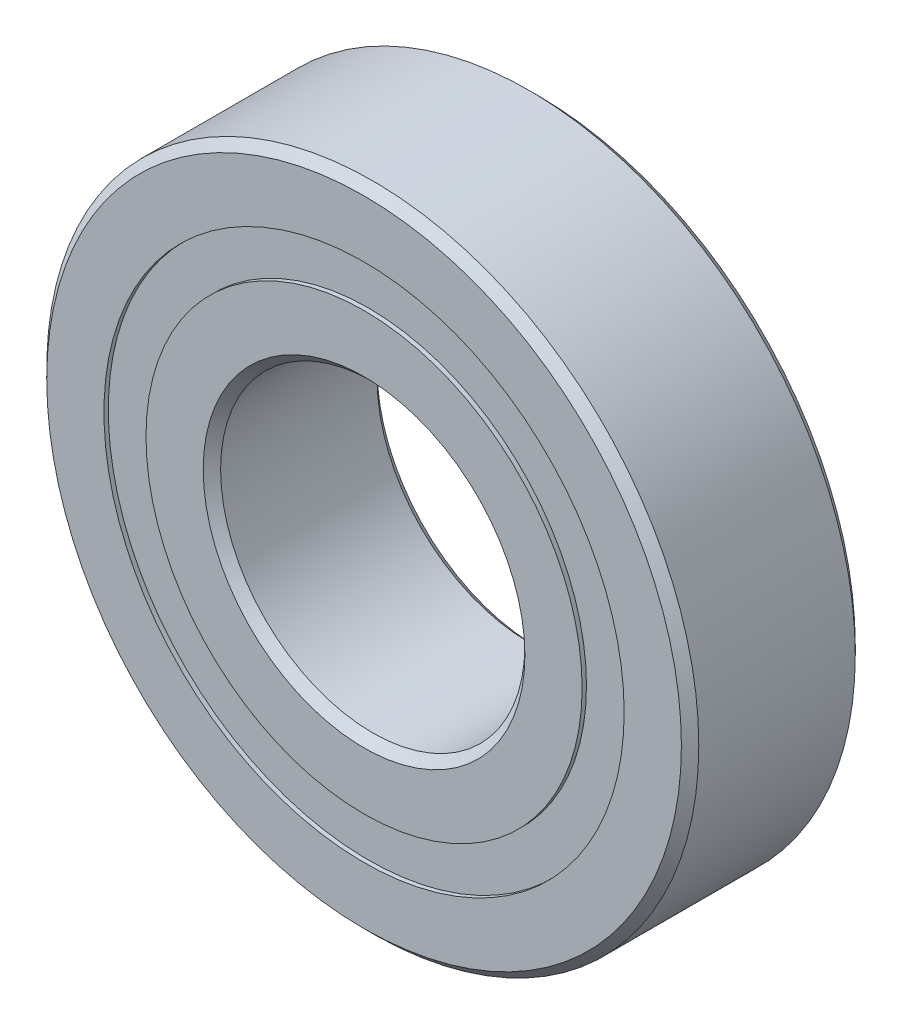
from build123d import *

# Parameters (mm, degrees)
CIRPATTERN1_COUNT = 12
SKETCH5_W         = 2.819764508
SKETCH5_H         = 3.07032967


with BuildPart() as part:
    # Sketch1 → Revolve1 (revolve)
    with BuildSketch(Plane(origin=(0, 0, 0), x_dir=(0, 0, -1), z_dir=(1, 0, 0))):
        with BuildLine():
            Line((5.715, 23.8125), (-5.715, 23.8125))
            Line((-5.715, 23.8125), (-6.35, 23.1775))
            Line((-6.35, 23.1775), (-6.35, 18.997664835))
            Line((-6.35, 18.997664835), (-2.822222222, 18.997664835))
            ThreePointArc((-2.822222222, 18.997664835), (0, 20.675235492), (2.822222222, 18.997664835))
            Line((2.822222222, 18.997664835), (6.35, 18.997664835))
            Line((6.35, 18.997664835), (6.35, 23.1775))
            Line((6.35, 23.1775), (5.715, 23.8125))
        make_face()
    revolve(axis=Axis((0, 0, 6.35), (0, 0, -1)))


with BuildPart() as body_2:
    # Sketch3 → Revolve3 (revolve)
    with BuildSketch(Plane(origin=(0, 0, 0), x_dir=(0, 0, -1), z_dir=(1, 0, 0))):
        with BuildLine():
            Line((-6.35, 15.927335165), (-2.822222222, 15.927335165))
            ThreePointArc((-2.822222222, 15.927335165), (0, 14.249764508), (2.822222222, 15.927335165))
            Line((2.822222222, 15.927335165), (6.35, 15.927335165))
            Line((6.35, 15.927335165), (6.35, 11.7475))
            Line((6.35, 11.7475), (5.715, 11.1125))
            Line((5.715, 11.1125), (-5.715, 11.1125))
            Line((-5.715, 11.1125), (-6.35, 11.7475))
            Line((-6.35, 11.7475), (-6.35, 15.927335165))
        make_face()
    revolve(axis=Axis((0, 0, 6.35), (0, 0, -1)))


with BuildPart() as body_3:
    # Sketch4 → Revolve4 (revolve)
    with BuildSketch(Plane(origin=(0, 0, 0), x_dir=(0, 0, -1), z_dir=(1, 0, 0))):
        with BuildLine():
            Line((-3.212735492, 17.4625), (3.212735492, 17.4625))
            ThreePointArc((3.212735492, 17.4625), (0, 20.675235492), (-3.212735492, 17.4625))
        make_face()
    revolve(axis=Axis((0, 17.4625, 3.212735492), (0, 0, -1)))


with BuildPart() as cirpattern1_1:
    # CirPattern1: pattern copy
    add(body_3.part.rotate(Axis((0, 0, -6.35), (0, 0, 1)), 1 * 360 / CIRPATTERN1_COUNT))


with BuildPart() as cirpattern1_2:
    # CirPattern1: pattern copy
    add(body_3.part.rotate(Axis((0, 0, -6.35), (0, 0, 1)), 2 * 360 / CIRPATTERN1_COUNT))


with BuildPart() as cirpattern1_3:
    # CirPattern1: pattern copy
    add(body_3.part.rotate(Axis((0, 0, -6.35), (0, 0, 1)), 3 * 360 / CIRPATTERN1_COUNT))


with BuildPart() as cirpattern1_4:
    # CirPattern1: pattern copy
    add(body_3.part.rotate(Axis((0, 0, -6.35), (0, 0, 1)), 4 * 360 / CIRPATTERN1_COUNT))


with BuildPart() as cirpattern1_5:
    # CirPattern1: pattern copy
    add(body_3.part.rotate(Axis((0, 0, -6.35), (0, 0, 1)), 5 * 360 / CIRPATTERN1_COUNT))


with BuildPart() as cirpattern1_6:
    # CirPattern1: pattern copy
    add(body_3.part.rotate(Axis((0, 0, -6.35), (0, 0, 1)), 6 * 360 / CIRPATTERN1_COUNT))


with BuildPart() as cirpattern1_7:
    # CirPattern1: pattern copy
    add(body_3.part.rotate(Axis((0, 0, -6.35), (0, 0, 1)), 7 * 360 / CIRPATTERN1_COUNT))


with BuildPart() as cirpattern1_8:
    # CirPattern1: pattern copy
    add(body_3.part.rotate(Axis((0, 0, -6.35), (0, 0, 1)), 8 * 360 / CIRPATTERN1_COUNT))


with BuildPart() as cirpattern1_9:
    # CirPattern1: pattern copy
    add(body_3.part.rotate(Axis((0, 0, -6.35), (0, 0, 1)), 9 * 360 / CIRPATTERN1_COUNT))


with BuildPart() as cirpattern1_10:
    # CirPattern1: pattern copy
    add(body_3.part.rotate(Axis((0, 0, -6.35), (0, 0, 1)), 10 * 360 / CIRPATTERN1_COUNT))


with BuildPart() as cirpattern1_11:
    # CirPattern1: pattern copy
    add(body_3.part.rotate(Axis((0, 0, -6.35), (0, 0, 1)), 11 * 360 / CIRPATTERN1_COUNT))


with BuildPart() as body_15:
    # Sketch5 → Revolve5 (revolve)
    with BuildSketch(Plane(origin=(0, 0, 0), x_dir=(0, 0, -1), z_dir=(1, 0, 0))):
        with Locations((-4.622617746, 17.4625)):
            Rectangle(SKETCH5_W, SKETCH5_H)
        with Locations((4.622617746, 17.4625)):
            Rectangle(SKETCH5_W, SKETCH5_H)
    revolve(axis=Axis((0, 0, 6.35), (0, 0, -1)))


solid = Compound([part.part, body_2.part, body_3.part, cirpattern1_1.part, cirpattern1_2.part, cirpattern1_3.part, cirpattern1_4.part, cirpattern1_5.part, cirpattern1_6.part, cirpattern1_7.part, cirpattern1_8.part, cirpattern1_9.part, cirpattern1_10.part, cirpattern1_11.part, body_15.part])
